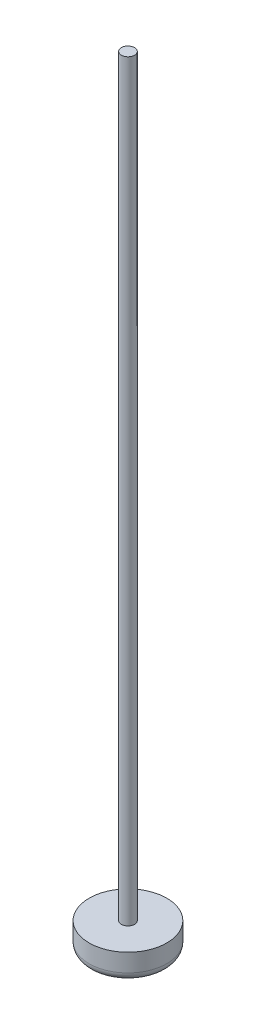
from build123d import *

# Parameters (mm, degrees)
SKETCH3_R           = 4.66725
BOSS_EXTRUDE1_DEPTH = 3.175
SKETCH4_R           = 0.79375
BOSS_EXTRUDE2_DEPTH = 90.4875
FILLET1_R           = 1.016


with BuildPart() as part:
    # Sketch3 → Boss-Extrude1 (new body)
    with BuildSketch(Plane(origin=(0, 0, 0), x_dir=(1, 0, 0), z_dir=(0, 1, 0))):
        Circle(SKETCH3_R)
    extrude(amount=BOSS_EXTRUDE1_DEPTH)

    # Sketch4 → Boss-Extrude2 (add)
    with BuildSketch(Plane(origin=(0, 3.175, 0), x_dir=(1, 0, 0), z_dir=(0, 1, 0))):
        Circle(SKETCH4_R)
    extrude(amount=BOSS_EXTRUDE2_DEPTH)

    # Fillet1
    fillet1_edges = [part.edges().sort_by_distance(p)[0] for p in [
        (-4.66725, 0, 0),
    ]]
    fillet(fillet1_edges, radius=FILLET1_R)


solid = part.part
